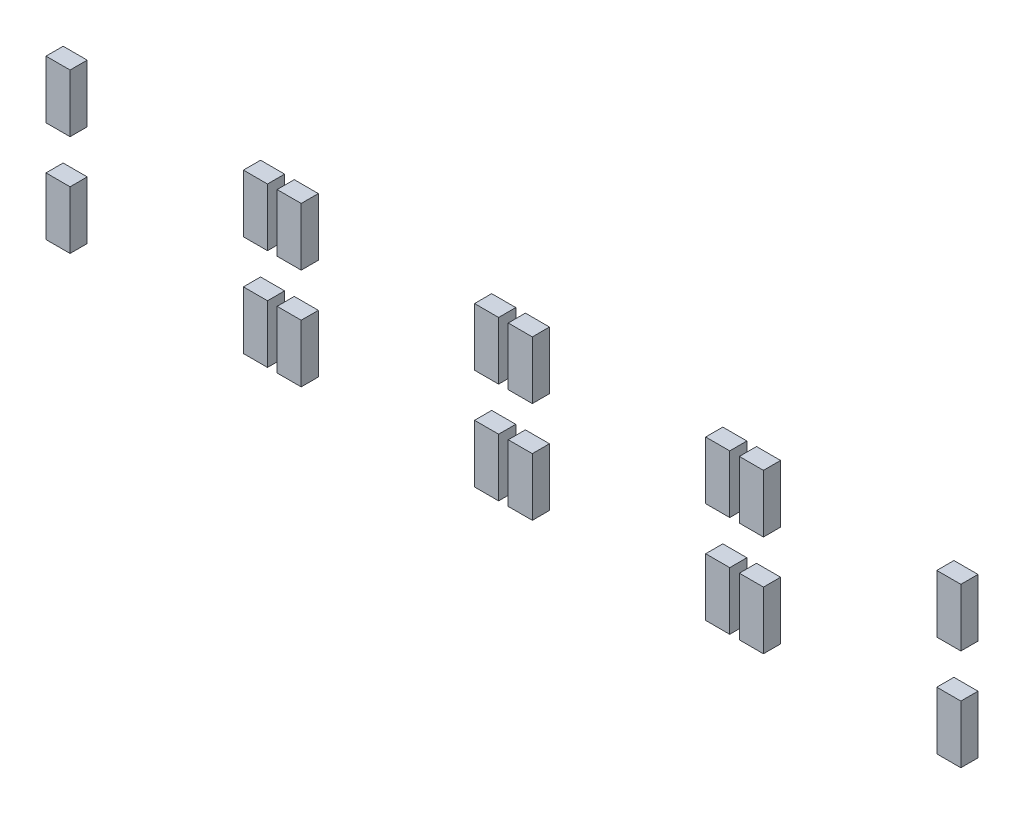
from build123d import *

# Parameters (mm, degrees)
SKETCH11_W             = 2.5
SKETCH11_H             = 6
BOSS_EXTRUDE5_DEPTH    = 1.78
BOSS_EXTRUDE5_2_DEPTH  = 1.78
BOSS_EXTRUDE5_3_DEPTH  = 1.78
BOSS_EXTRUDE5_4_DEPTH  = 1.78
BOSS_EXTRUDE5_5_DEPTH  = 1.78
BOSS_EXTRUDE5_6_DEPTH  = 1.78
BOSS_EXTRUDE5_7_DEPTH  = 1.78
BOSS_EXTRUDE5_8_DEPTH  = 1.78
BOSS_EXTRUDE5_9_DEPTH  = 1.78
BOSS_EXTRUDE5_10_DEPTH = 1.78
BOSS_EXTRUDE5_11_DEPTH = 1.78
BOSS_EXTRUDE5_12_DEPTH = 1.78
BOSS_EXTRUDE5_13_DEPTH = 1.78
BOSS_EXTRUDE5_14_DEPTH = 1.78
BOSS_EXTRUDE5_15_DEPTH = 1.78
BOSS_EXTRUDE5_16_DEPTH = 1.78


with BuildPart() as part:
    # Sketch11 → Boss-Extrude5 (new body)
    with BuildSketch(Plane.XY.offset(-1.5875)):
        with Locations((24.25, -45)):
            Rectangle(SKETCH11_W, SKETCH11_H)
    extrude(amount=-BOSS_EXTRUDE5_DEPTH)


with BuildPart() as body_2:
    # Sketch11 → Boss-Extrude5 2 (new body)
    with BuildSketch(Plane.XY.offset(-1.5875)):
        with Locations((3.75, -45)):
            Rectangle(SKETCH11_W, SKETCH11_H)
    extrude(amount=-BOSS_EXTRUDE5_2_DEPTH)


with BuildPart() as body_3:
    # Sketch11 → Boss-Extrude5 3 (new body)
    with BuildSketch(Plane.XY.offset(-1.5875)):
        with Locations((3.75, -55.5)):
            Rectangle(SKETCH11_W, SKETCH11_H)
    extrude(amount=-BOSS_EXTRUDE5_3_DEPTH)


with BuildPart() as body_4:
    # Sketch11 → Boss-Extrude5 4 (new body)
    with BuildSketch(Plane.XY.offset(-1.5875)):
        with Locations((24.25, -55.5)):
            Rectangle(SKETCH11_W, SKETCH11_H)
    extrude(amount=-BOSS_EXTRUDE5_4_DEPTH)


with BuildPart() as body_5:
    # Sketch11 → Boss-Extrude5 5 (new body)
    with BuildSketch(Plane.XY.offset(-1.5875)):
        with Locations((48.25, -45)):
            Rectangle(SKETCH11_W, SKETCH11_H)
    extrude(amount=-BOSS_EXTRUDE5_5_DEPTH)


with BuildPart() as body_6:
    # Sketch11 → Boss-Extrude5 6 (new body)
    with BuildSketch(Plane.XY.offset(-1.5875)):
        with Locations((27.75, -45)):
            Rectangle(SKETCH11_W, SKETCH11_H)
    extrude(amount=-BOSS_EXTRUDE5_6_DEPTH)


with BuildPart() as body_7:
    # Sketch11 → Boss-Extrude5 7 (new body)
    with BuildSketch(Plane.XY.offset(-1.5875)):
        with Locations((27.75, -55.5)):
            Rectangle(SKETCH11_W, SKETCH11_H)
    extrude(amount=-BOSS_EXTRUDE5_7_DEPTH)


with BuildPart() as body_8:
    # Sketch11 → Boss-Extrude5 8 (new body)
    with BuildSketch(Plane.XY.offset(-1.5875)):
        with Locations((48.25, -55.5)):
            Rectangle(SKETCH11_W, SKETCH11_H)
    extrude(amount=-BOSS_EXTRUDE5_8_DEPTH)


with BuildPart() as body_9:
    # Sketch11 → Boss-Extrude5 9 (new body)
    with BuildSketch(Plane.XY.offset(-1.5875)):
        with Locations((72.25, -45)):
            Rectangle(SKETCH11_W, SKETCH11_H)
    extrude(amount=-BOSS_EXTRUDE5_9_DEPTH)


with BuildPart() as body_10:
    # Sketch11 → Boss-Extrude5 10 (new body)
    with BuildSketch(Plane.XY.offset(-1.5875)):
        with Locations((51.75, -45)):
            Rectangle(SKETCH11_W, SKETCH11_H)
    extrude(amount=-BOSS_EXTRUDE5_10_DEPTH)


with BuildPart() as body_11:
    # Sketch11 → Boss-Extrude5 11 (new body)
    with BuildSketch(Plane.XY.offset(-1.5875)):
        with Locations((51.75, -55.5)):
            Rectangle(SKETCH11_W, SKETCH11_H)
    extrude(amount=-BOSS_EXTRUDE5_11_DEPTH)


with BuildPart() as body_12:
    # Sketch11 → Boss-Extrude5 12 (new body)
    with BuildSketch(Plane.XY.offset(-1.5875)):
        with Locations((72.25, -55.5)):
            Rectangle(SKETCH11_W, SKETCH11_H)
    extrude(amount=-BOSS_EXTRUDE5_12_DEPTH)


with BuildPart() as body_13:
    # Sketch11 → Boss-Extrude5 13 (new body)
    with BuildSketch(Plane.XY.offset(-1.5875)):
        with Locations((96.25, -45)):
            Rectangle(SKETCH11_W, SKETCH11_H)
    extrude(amount=-BOSS_EXTRUDE5_13_DEPTH)


with BuildPart() as body_14:
    # Sketch11 → Boss-Extrude5 14 (new body)
    with BuildSketch(Plane.XY.offset(-1.5875)):
        with Locations((75.75, -45)):
            Rectangle(SKETCH11_W, SKETCH11_H)
    extrude(amount=-BOSS_EXTRUDE5_14_DEPTH)


with BuildPart() as body_15:
    # Sketch11 → Boss-Extrude5 15 (new body)
    with BuildSketch(Plane.XY.offset(-1.5875)):
        with Locations((75.75, -55.5)):
            Rectangle(SKETCH11_W, SKETCH11_H)
    extrude(amount=-BOSS_EXTRUDE5_15_DEPTH)


with BuildPart() as body_16:
    # Sketch11 → Boss-Extrude5 16 (new body)
    with BuildSketch(Plane.XY.offset(-1.5875)):
        with Locations((96.25, -55.5)):
            Rectangle(SKETCH11_W, SKETCH11_H)
    extrude(amount=-BOSS_EXTRUDE5_16_DEPTH)


solid = Compound([part.part, body_2.part, body_3.part, body_4.part, body_5.part, body_6.part, body_7.part, body_8.part, body_9.part, body_10.part, body_11.part, body_12.part, body_13.part, body_14.part, body_15.part, body_16.part])
